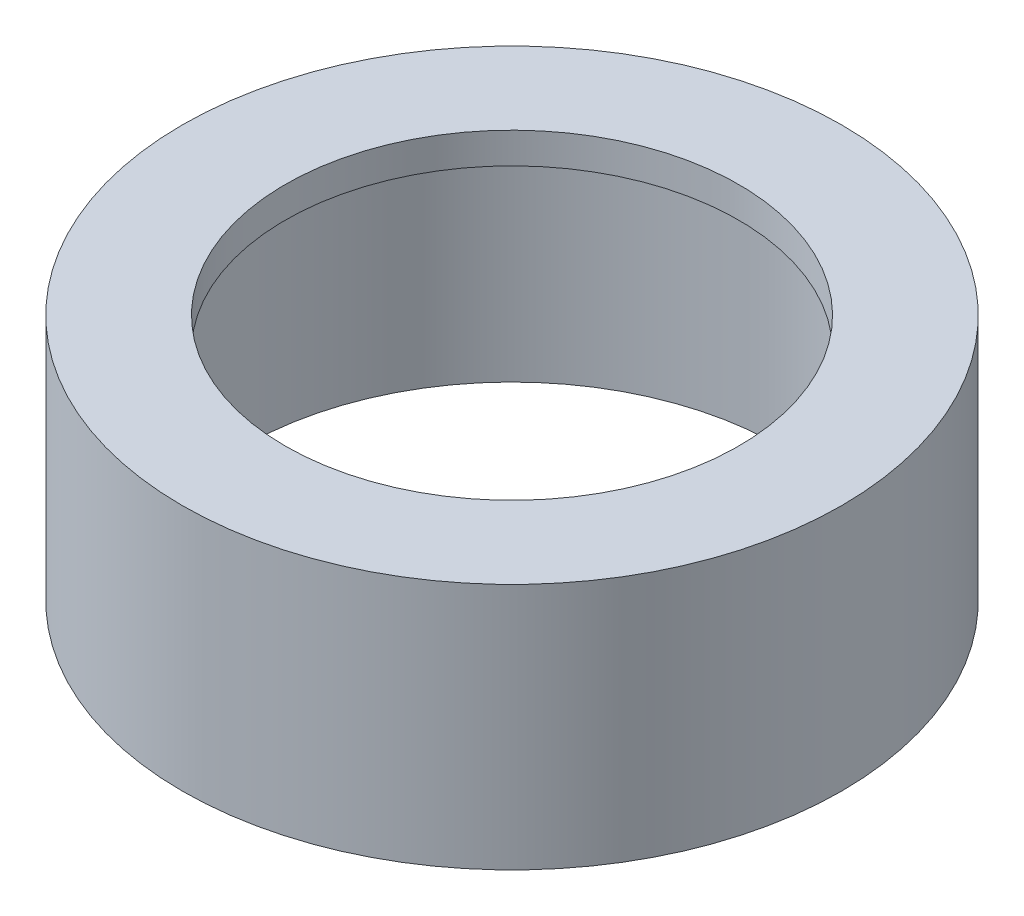
from build123d import *

# Parameters (mm, degrees)
SKETCH1_R           = 16
SKETCH1_R_2         = 13
BOSS_EXTRUDE1_DEPTH = 12
SKETCH2_R           = 13
SKETCH2_R_2         = 11
BOSS_EXTRUDE2_DEPTH = 1.5


with BuildPart() as part:
    # Sketch1 → Boss-Extrude1 (new body)
    with BuildSketch(Plane(origin=(0, 0, 0), x_dir=(1, 0, 0), z_dir=(0, 1, 0))):
        Circle(SKETCH1_R)
        Circle(SKETCH1_R_2, mode=Mode.SUBTRACT)
    extrude(amount=BOSS_EXTRUDE1_DEPTH)

    # Sketch2 → Boss-Extrude2 (add)
    with BuildSketch(Plane(origin=(0, 12, 0), x_dir=(1, 0, 0), z_dir=(0, 1, 0))):
        Circle(SKETCH2_R)
        Circle(SKETCH2_R_2, mode=Mode.SUBTRACT)
    extrude(amount=-BOSS_EXTRUDE2_DEPTH)


solid = part.part
